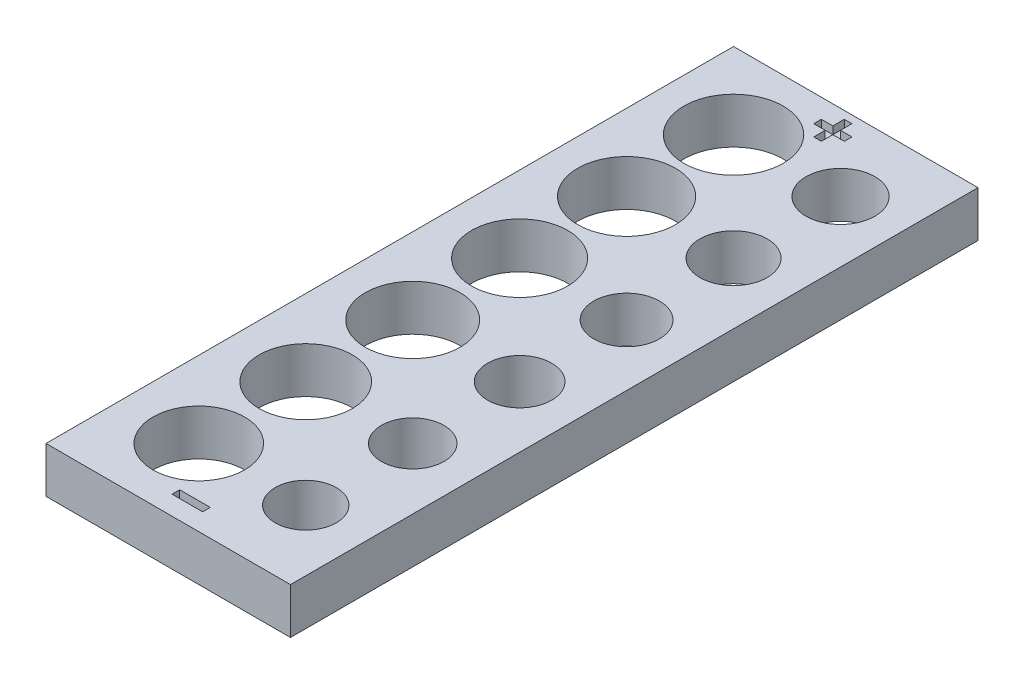
from build123d import *

# Parameters (mm, degrees)
SKETCH1_W           = 16
SKETCH1_H           = 45
SKETCH1_R           = 3
SKETCH1_R_2         = 3.05
SKETCH1_R_3         = 3.1
SKETCH1_R_4         = 3.15
SKETCH1_R_5         = 3.2
SKETCH1_R_6         = 3.25
SKETCH1_R_7         = 2.25
SKETCH1_R_8         = 2.2
SKETCH1_R_9         = 2.15
SKETCH1_R_10        = 2.1
SKETCH1_R_11        = 2.05
SKETCH1_R_12        = 2
BOSS_EXTRUDE1_DEPTH = 3
SKETCH2_W           = 2
SKETCH2_H           = 0.5
CUT_EXTRUDE1_DEPTH  = 0.5


with BuildPart() as part:
    # Sketch1 → Boss-Extrude1 (new body)
    with BuildSketch(Plane(origin=(0, 0, 0), x_dir=(1, 0, 0), z_dir=(0, 1, 0))):
        with Locations((8, 22.5)):
            Rectangle(SKETCH1_W, SKETCH1_H)
        with Locations((5, 5)):
            Circle(SKETCH1_R, mode=Mode.SUBTRACT)
        with Locations((5, 12)):
            Circle(SKETCH1_R_2, mode=Mode.SUBTRACT)
        with Locations((5, 19)):
            Circle(SKETCH1_R_3, mode=Mode.SUBTRACT)
        with Locations((5, 26)):
            Circle(SKETCH1_R_4, mode=Mode.SUBTRACT)
        with Locations((5, 33)):
            Circle(SKETCH1_R_5, mode=Mode.SUBTRACT)
        with Locations((5, 40)):
            Circle(SKETCH1_R_6, mode=Mode.SUBTRACT)
        with Locations((12, 40)):
            Circle(SKETCH1_R_7, mode=Mode.SUBTRACT)
        with Locations((12, 33)):
            Circle(SKETCH1_R_8, mode=Mode.SUBTRACT)
        with Locations((12, 26)):
            Circle(SKETCH1_R_9, mode=Mode.SUBTRACT)
        with Locations((12, 19)):
            Circle(SKETCH1_R_10, mode=Mode.SUBTRACT)
        with Locations((12, 12)):
            Circle(SKETCH1_R_11, mode=Mode.SUBTRACT)
        with Locations((12, 5)):
            Circle(SKETCH1_R_12, mode=Mode.SUBTRACT)
    extrude(amount=BOSS_EXTRUDE1_DEPTH)

    # Sketch2 → Cut-Extrude1 (cut)
    with BuildSketch(Plane(origin=(0, 3, 0), x_dir=(1, 0, 0), z_dir=(0, 1, 0))):
        Polygon((7.75, 43.75), (7.75, 44.5), (8.25, 44.5), (8.25, 43.75), (9, 43.75), (9, 43.25), (8.25, 43.25), (8.25, 42.5), (7.75, 42.5), (7.75, 43.25), (7, 43.25), (7, 43.75), align=None)
        with Locations((8, 1.5)):
            Rectangle(SKETCH2_W, SKETCH2_H)
    extrude(amount=-CUT_EXTRUDE1_DEPTH, mode=Mode.SUBTRACT)


solid = part.part
